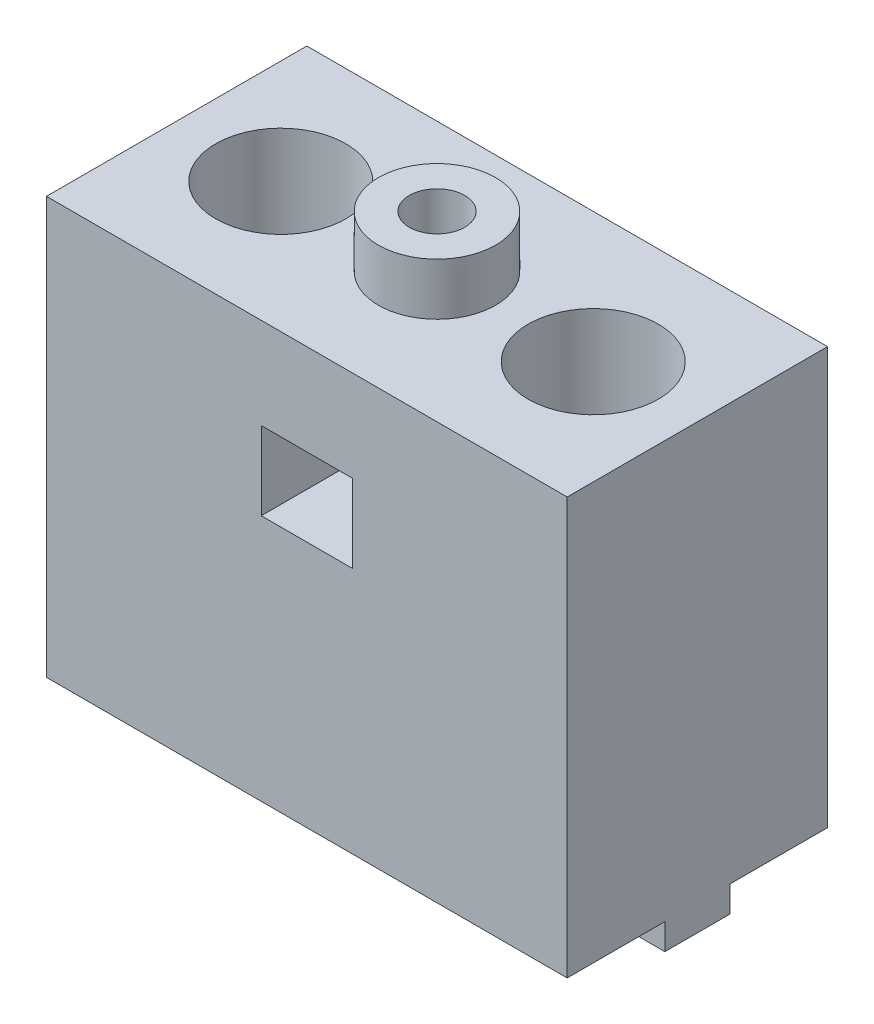
from build123d import *

# Parameters (mm, degrees)
SKETCH1_W           = 40
SKETCH1_H           = 20
BOSS_EXTRUDE1_DEPTH = 32
SKETCH2_W           = 40
SKETCH2_H           = 5
BOSS_EXTRUDE2_DEPTH = 2
SKETCH3_R           = 2.75
CUT_EXTRUDE1_DEPTH  = 35
SKETCH4_R           = 5
CUT_EXTRUDE2_DEPTH  = 27
SKETCH5_W           = 7
SKETCH5_H           = 6
CUT_EXTRUDE3_DEPTH  = 21
SKETCH6_R           = 4.5
BOSS_EXTRUDE3_DEPTH = 4
SKETCH7_R           = 2.125
CUT_EXTRUDE4_DEPTH  = 20


with BuildPart() as part:
    # Sketch1 → Boss-Extrude1 (new body)
    with BuildSketch(Plane(origin=(0, 0, 0), x_dir=(1, 0, 0), z_dir=(0, 1, 0))):
        with Locations((20, 10)):
            Rectangle(SKETCH1_W, SKETCH1_H)
    extrude(amount=BOSS_EXTRUDE1_DEPTH)

    # Sketch2 → Boss-Extrude2 (add)
    with BuildSketch(Plane.XZ):
        with Locations((20, -10)):
            Rectangle(SKETCH2_W, SKETCH2_H)
    extrude(amount=BOSS_EXTRUDE2_DEPTH)

    # Sketch3 → Cut-Extrude1 (cut, through all)
    with BuildSketch(Plane(origin=(0, 32, 0), x_dir=(1, 0, 0), z_dir=(0, 1, 0))):
        with Locations((32, 10)):
            Circle(SKETCH3_R)
        with Locations((8, 10)):
            Circle(SKETCH3_R)
    extrude(amount=-CUT_EXTRUDE1_DEPTH, mode=Mode.SUBTRACT)

    # Sketch4 → Cut-Extrude2 (cut)
    with BuildSketch(Plane(origin=(0, 32, 0), x_dir=(1, 0, 0), z_dir=(0, 1, 0))):
        with Locations((8, 10)):
            Circle(SKETCH4_R)
        with Locations((32, 10)):
            Circle(SKETCH4_R)
    extrude(amount=-CUT_EXTRUDE2_DEPTH, mode=Mode.SUBTRACT)

    # Sketch5 → Cut-Extrude3 (cut, through all)
    with BuildSketch(Plane.XY):
        with Locations((20, 22)):
            Rectangle(SKETCH5_W, SKETCH5_H)
    extrude(amount=-CUT_EXTRUDE3_DEPTH, mode=Mode.SUBTRACT)

    # Sketch6 → Boss-Extrude3 (add)
    with BuildSketch(Plane(origin=(0, 32, 0), x_dir=(1, 0, 0), z_dir=(0, 1, 0))):
        with Locations((20, 10)):
            Circle(SKETCH6_R)
    extrude(amount=BOSS_EXTRUDE3_DEPTH)

    # Sketch7 → Cut-Extrude4 (cut)
    with BuildSketch(Plane(origin=(0, 36, 0), x_dir=(1, 0, 0), z_dir=(0, 1, 0))):
        with Locations((20, 10)):
            Circle(SKETCH7_R)
    extrude(amount=-CUT_EXTRUDE4_DEPTH, mode=Mode.SUBTRACT)


solid = part.part
